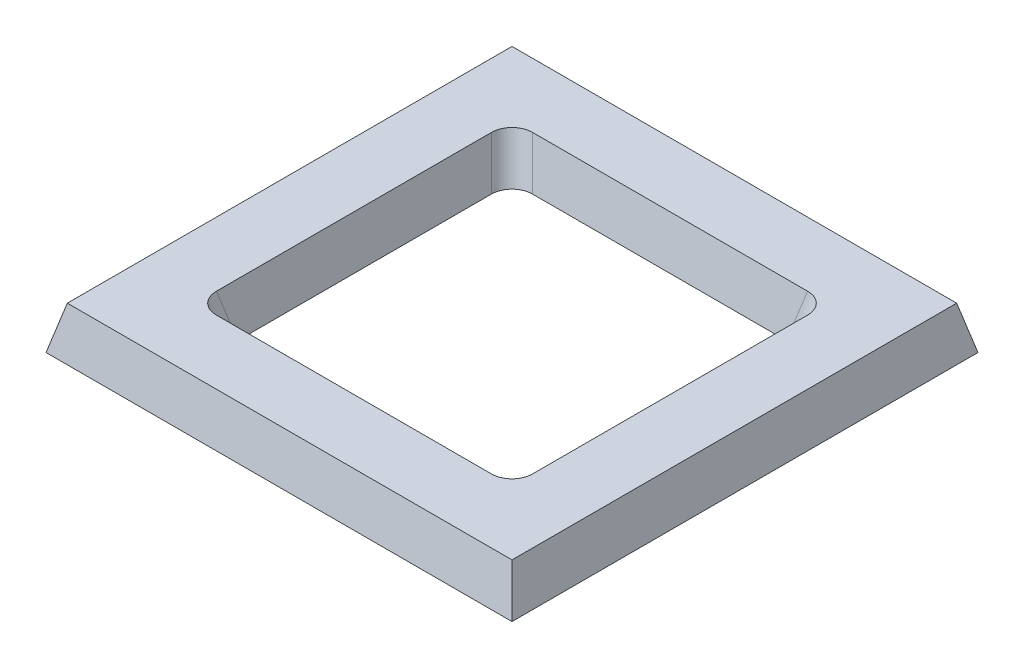
from build123d import *

# Parameters (mm, degrees)
SKETCH1_W           = 109
SKETCH1_H           = 109
SKETCH1_W_2         = 69
SKETCH1_H_2         = 69
EXTRUDE_THIN1_DEPTH = 10
EXTRUDE_THIN1_TAPER = 14
FILLET1_R           = 5


with BuildPart() as part:
    # Sketch1 → Extrude-Thin1 (new body)
    with BuildSketch(Plane(origin=(0, 0, 0), x_dir=(1, 0, 0), z_dir=(0, 1, 0))):
        Rectangle(SKETCH1_W, SKETCH1_H)
        Rectangle(SKETCH1_W_2, SKETCH1_H_2, mode=Mode.SUBTRACT)
    extrude(amount=EXTRUDE_THIN1_DEPTH, taper=EXTRUDE_THIN1_TAPER)

    # Fillet1
    fillet1_edges = [part.edges().sort_by_distance(p)[0] for p in [
        (35.746640014, 5, 35.746640014),
        (35.746640014, 5, -35.746640014),
        (-35.746640014, 5, -35.746640014),
        (-35.746640014, 5, 35.746640014),
    ]]
    fillet(fillet1_edges, radius=FILLET1_R)


solid = part.part
